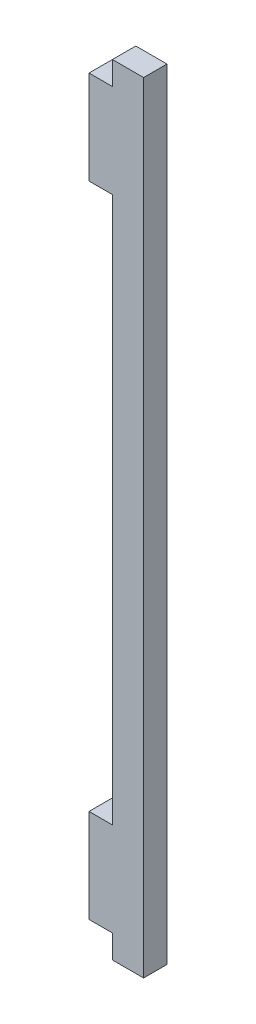
from build123d import *

# Parameters (mm, degrees)
SALIENTE_EXTRUIR1_DEPTH = 3


with BuildPart() as part:
    # Croquis1 → Saliente-Extruir1 (new body)
    with BuildSketch(Plane.XY):
        Polygon((0, 0), (4, 0), (4, 100), (0, 100), (0, 97), (-3, 97), (-3, 85), (0, 85), (0, 15), (-3, 15), (-3, 3), (0, 3), align=None)
    extrude(amount=SALIENTE_EXTRUIR1_DEPTH)


solid = part.part
